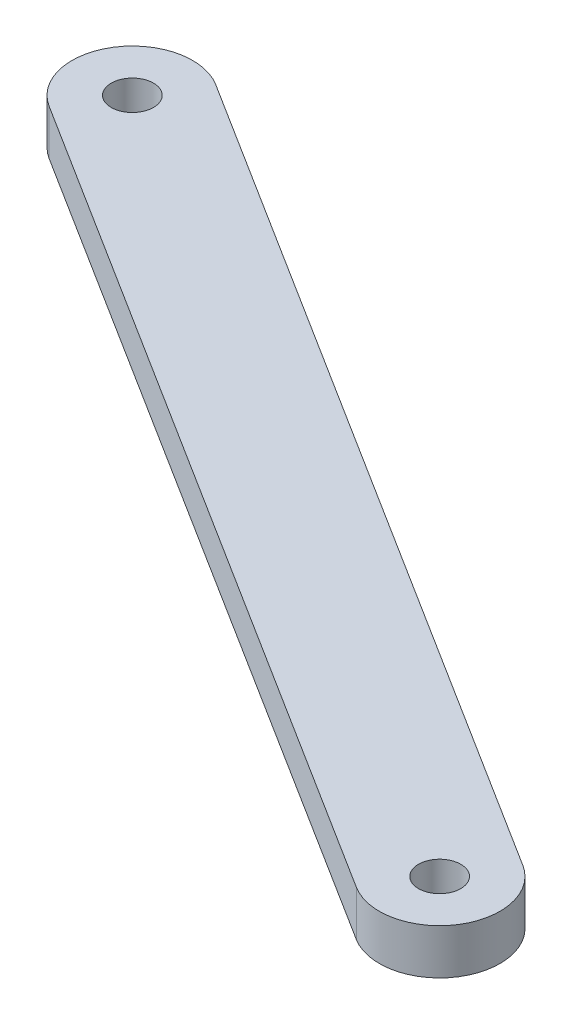
from build123d import *

# Parameters (mm, degrees)
SKETCH1_R           = 1.4
BOSS_EXTRUDE1_DEPTH = 3


with BuildPart() as part:
    # Sketch1 → Boss-Extrude1 (new body)
    with BuildSketch(Plane(origin=(0, 0, 0), x_dir=(1, 0, 0), z_dir=(0, 1, 0))):
        with BuildLine():
            Line((-2.1321761, -19.496728679), (-57.1321761, 15.144287473))
            ThreePointArc((-57.1321761, 15.144287473), (-62.648546324, 13.891426928), (-61.39568578, 8.375056704))
            Line((-61.39568578, 8.375056704), (-6.39568578, -26.265959448))
            ThreePointArc((-6.39568578, -26.265959448), (-0.879315555, -25.013098903), (-2.1321761, -19.496728679))
        make_face()
        with Locations((-4.26393094, -22.881344063)):
            Circle(SKETCH1_R, mode=Mode.SUBTRACT)
        with Locations((-59.26393094, 11.759672088)):
            Circle(SKETCH1_R, mode=Mode.SUBTRACT)
    extrude(amount=BOSS_EXTRUDE1_DEPTH)


solid = part.part
